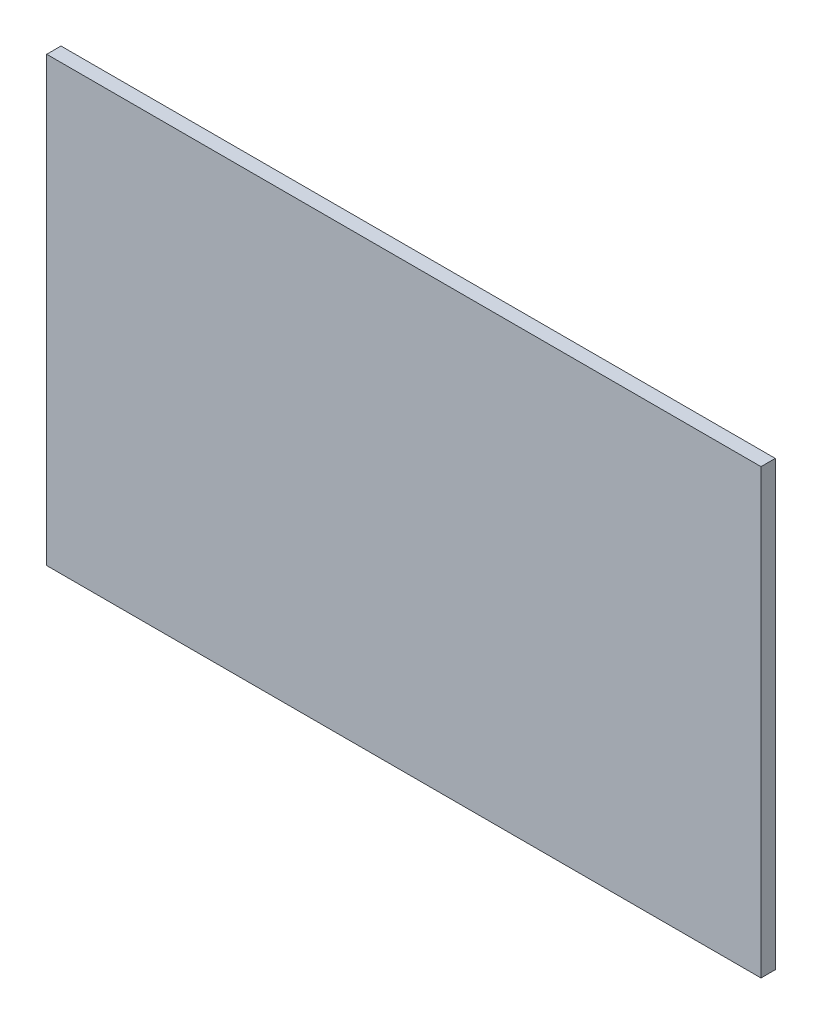
from build123d import *

# Parameters (mm, degrees)
SKETCH1_W           = 500
SKETCH1_H           = 310
BOSS_EXTRUDE1_DEPTH = 10


with BuildPart() as part:
    # Sketch1 → Boss-Extrude1 (new body)
    with BuildSketch(Plane.XY):
        Rectangle(SKETCH1_W, SKETCH1_H)
    extrude(amount=BOSS_EXTRUDE1_DEPTH)


solid = part.part
